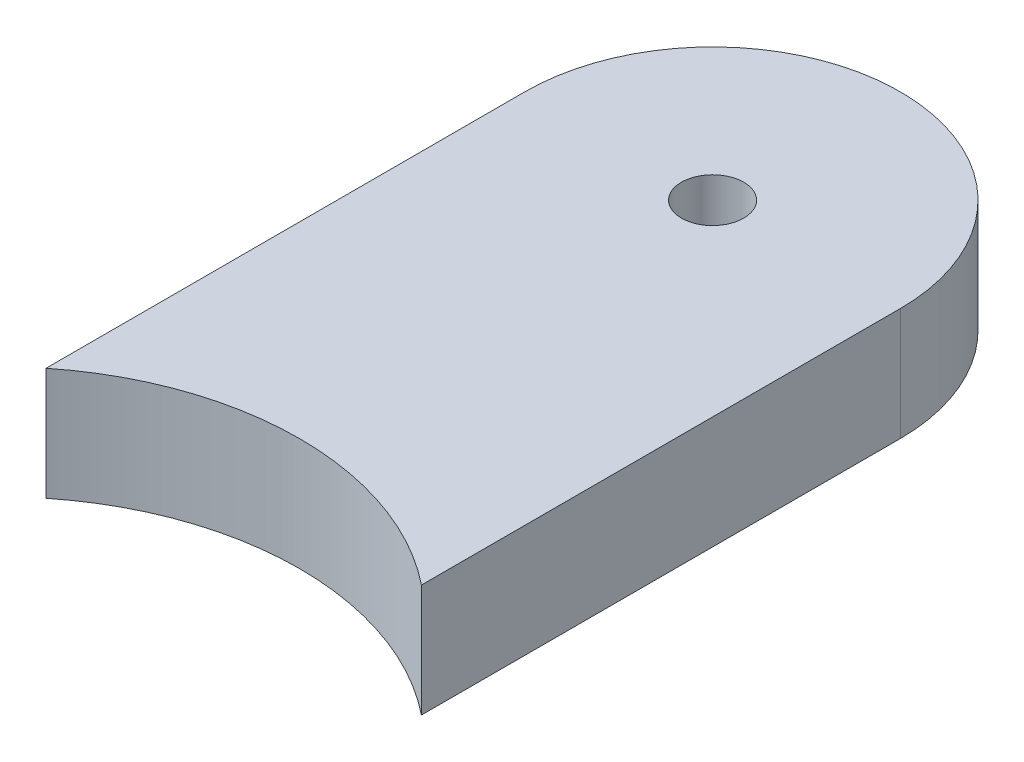
from build123d import *

# Parameters (mm, degrees)
ESQUISSE1_R        = 4.15
BOSS_EXTRU_1_DEPTH = 15


with BuildPart() as part:
    # Esquisse1 → Boss.-Extru.1 (new body)
    with BuildSketch(Plane(origin=(0, 0, 0), x_dir=(1, 0, 0), z_dir=(0, 1, 0))):
        with BuildLine():
            Line((25, 31.224989992), (25, 95))
            ThreePointArc((25, 95), (0, 120), (-25, 95))
            Line((-25, 95), (-25, 31.224989992))
            ThreePointArc((-25, 31.224989992), (0, 40), (25, 31.224989992))
        make_face()
        with Locations(Location((0, 95, 0), (0, 0, 270))):  # turned: the seam where the file's is
            Circle(ESQUISSE1_R, mode=Mode.SUBTRACT)
    extrude(amount=BOSS_EXTRU_1_DEPTH)


solid = part.part
